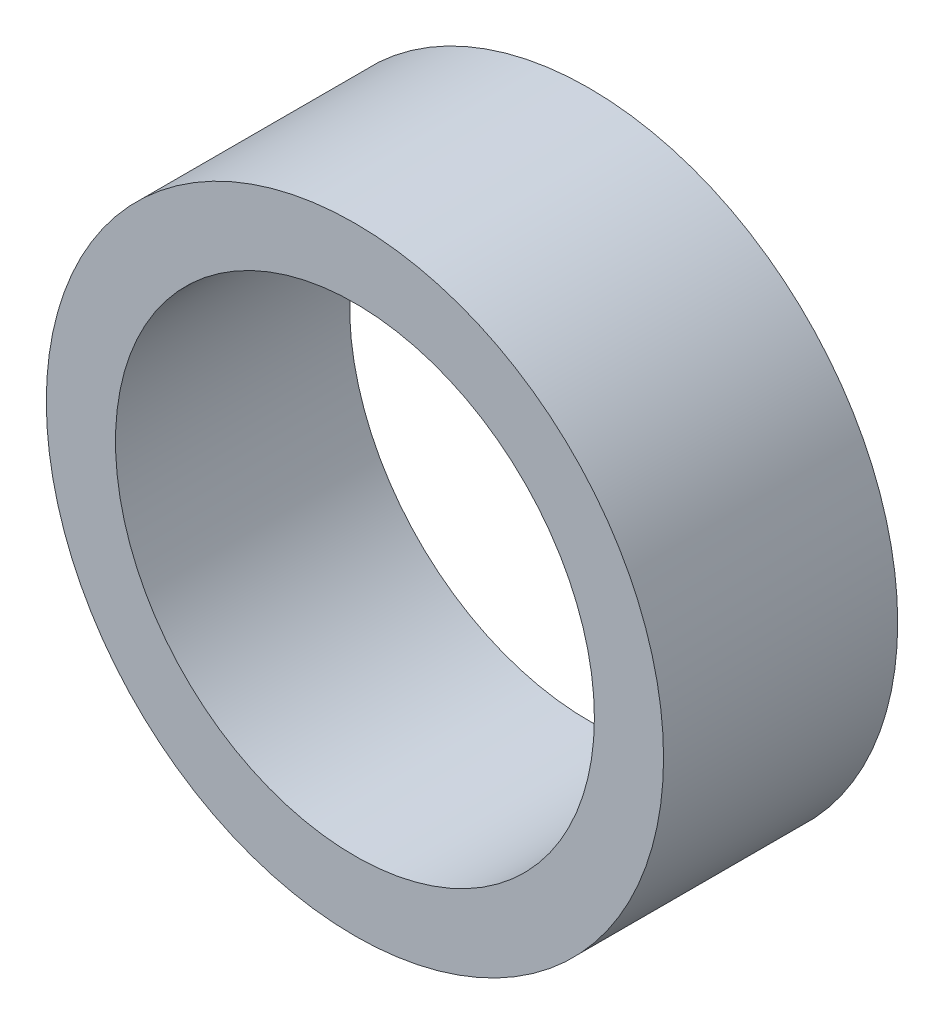
from build123d import *

# Parameters (mm, degrees)
SKETCH_1_R      = 29
SKETCH_1_R_2    = 22.5
EXTRUDE_1_DEPTH = 22


with BuildPart() as part:
    # 草图1 → 凸台-拉伸1 (new body)
    with BuildSketch(Plane.XY):
        Circle(SKETCH_1_R)
        Circle(SKETCH_1_R_2, mode=Mode.SUBTRACT)
    extrude(amount=EXTRUDE_1_DEPTH)


solid = part.part
